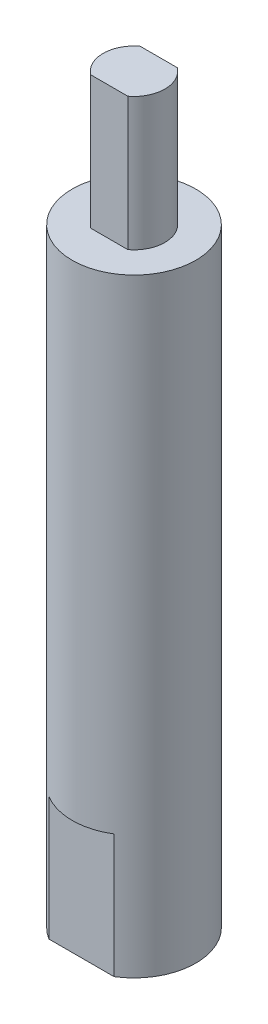
from build123d import *

# Parameters (mm, degrees)
ESQUISSE1_R                  = 10
BOSS_EXTRU_1_DEPTH           = 120
ESQUISSE2_R                  = 10
ESQUISSE2_R_2                = 5
ENL_V_MAT_EXTRU_1_DEPTH      = 21.5
TROU_TARAUD_M101_D           = 8.5
TROU_TARAUD_M101_DEPTH       = 35
TROU_TARAUD_M101_CSINK_D     = 10.05
TROU_TARAUD_M101_CSINK_ANGLE = 90
TROU_TARAUD_M101_TIP         = 2.553657631
ESQUISSE14_W                 = 20
ESQUISSE14_H                 = 1.5
ENL_V_MAT_EXTRU_2_DEPTH      = 20
ESQUISSE15_W                 = 20
ESQUISSE15_H                 = 1
ENL_V_MAT_EXTRU_5_DEPTH      = 21.5


with BuildPart() as part:
    # Esquisse1 → Boss.-Extru.1 (new body)
    with BuildSketch(Plane(origin=(0, 0, 0), x_dir=(1, 0, 0), z_dir=(0, 1, 0))):
        with Locations(Location((0, 0, 0), (0, 0, 270))):  # turned: the seam where the file's is
            Circle(ESQUISSE1_R)
    extrude(amount=BOSS_EXTRU_1_DEPTH)

    # Esquisse2 → Enlèv. mat.-Extru.1 (cut)
    with BuildSketch(Plane(origin=(0, 120, 0), x_dir=(1, 0, 0), z_dir=(0, 1, 0))):
        with Locations(Location((0, 0, 0), (0, 0, 270))):  # turned: the seam where the file's is
            Circle(ESQUISSE2_R)
        with Locations(Location((0, 0, 0), (0, 0, 270))):  # turned: the seam where the file's is
            Circle(ESQUISSE2_R_2, mode=Mode.SUBTRACT)
    extrude(amount=-ENL_V_MAT_EXTRU_1_DEPTH, mode=Mode.SUBTRACT)

    # Trou taraudé M101
    with Locations(Plane(origin=(0, 0, 0), x_dir=(-1, 0, 0), z_dir=(0, -1, 0))):
        with Locations((0, 0)):
            CounterSinkHole(TROU_TARAUD_M101_D / 2, TROU_TARAUD_M101_CSINK_D / 2, depth=TROU_TARAUD_M101_DEPTH, counter_sink_angle=TROU_TARAUD_M101_CSINK_ANGLE)
            with Locations((0, 0, -(TROU_TARAUD_M101_DEPTH + TROU_TARAUD_M101_TIP / 2))):  # 118° drill point
                Cone(0, TROU_TARAUD_M101_D / 2, TROU_TARAUD_M101_TIP, mode=Mode.SUBTRACT)

    # Esquisse14 → Enlèv. mat.-Extru.2 (cut)
    with BuildSketch(Plane.XZ):
        with Locations((0, 9.25)):
            Rectangle(ESQUISSE14_W, ESQUISSE14_H)
        with Locations((0, -9.25)):
            Rectangle(ESQUISSE14_W, ESQUISSE14_H)
    extrude(amount=-ENL_V_MAT_EXTRU_2_DEPTH, mode=Mode.SUBTRACT)

    # Esquisse15 → Enlèv. mat.-Extru.5 (cut)
    with BuildSketch(Plane(origin=(0, 120, 0), x_dir=(1, 0, 0), z_dir=(0, 1, 0))):
        with Locations((0, 4.5)):
            Rectangle(ESQUISSE15_W, ESQUISSE15_H)
        with Locations((0, -4.5)):
            Rectangle(ESQUISSE15_W, ESQUISSE15_H)
    extrude(amount=-ENL_V_MAT_EXTRU_5_DEPTH, mode=Mode.SUBTRACT)


solid = part.part
